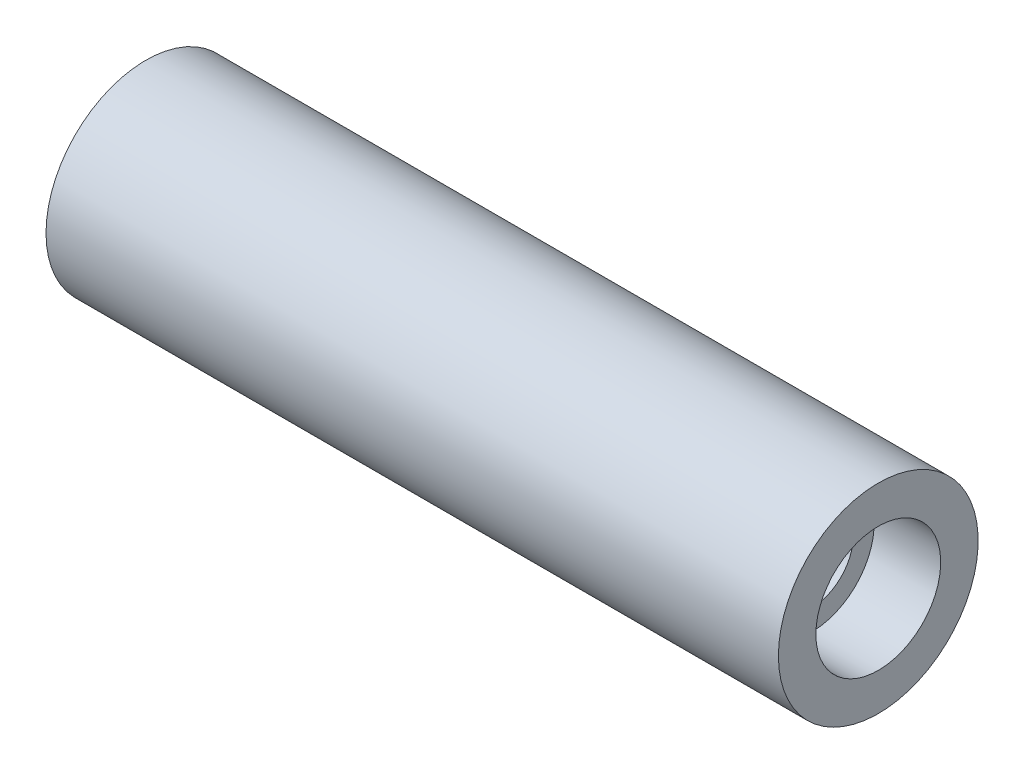
from build123d import *


with BuildPart() as part:
    # Sketch1 → Revolve1 (revolve)
    with BuildSketch(Plane.XY):
        Polygon((0, 3.175), (50.8, 3.175), (50.8, 4.7625), (55.88, 4.7625), (55.88, 7.62), (0, 7.62), align=None)
    revolve(axis=Axis((236.984173224, 0, 0), (1, 0, 0)))


solid = part.part
